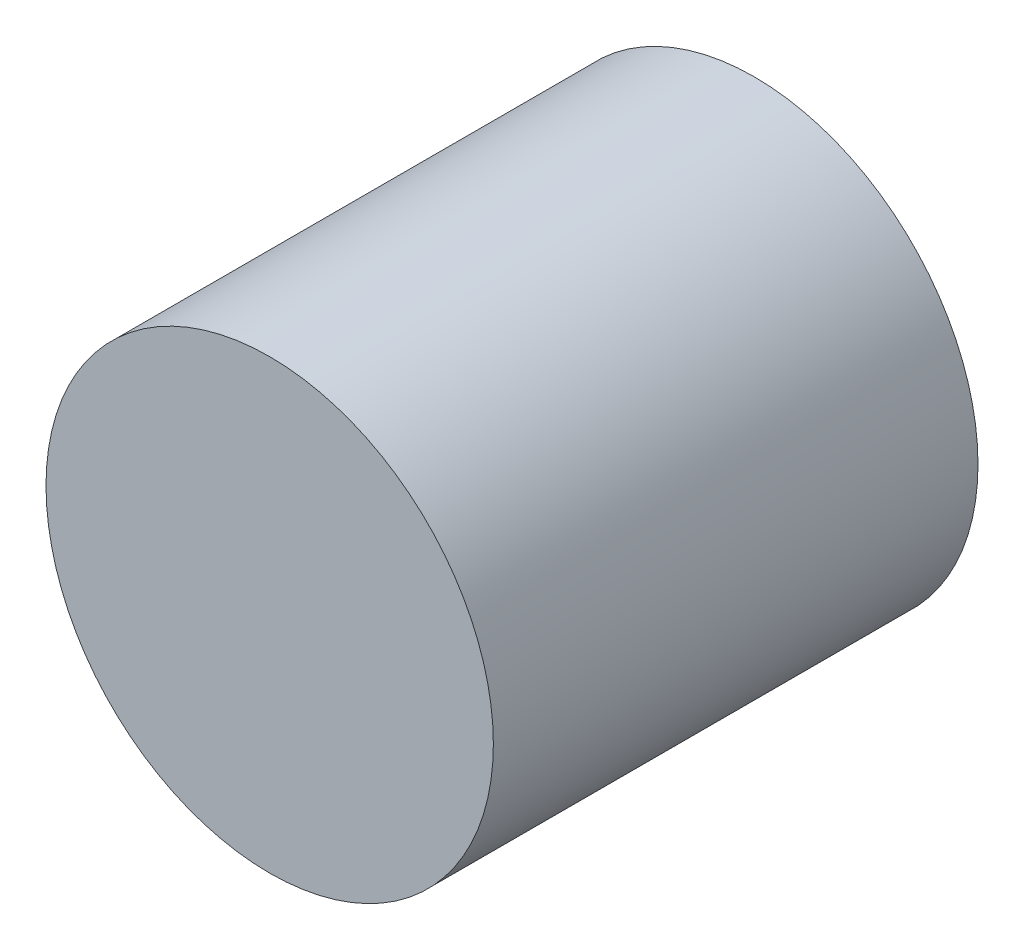
from build123d import *

# Parameters (mm, degrees)
SKETCH1_R           = 3
BOSS_EXTRUDE1_DEPTH = 6.5


with BuildPart() as part:
    # Sketch1 → Boss-Extrude1 (new body)
    with BuildSketch(Plane.XY):
        Circle(SKETCH1_R)
    extrude(amount=BOSS_EXTRUDE1_DEPTH)


solid = part.part
